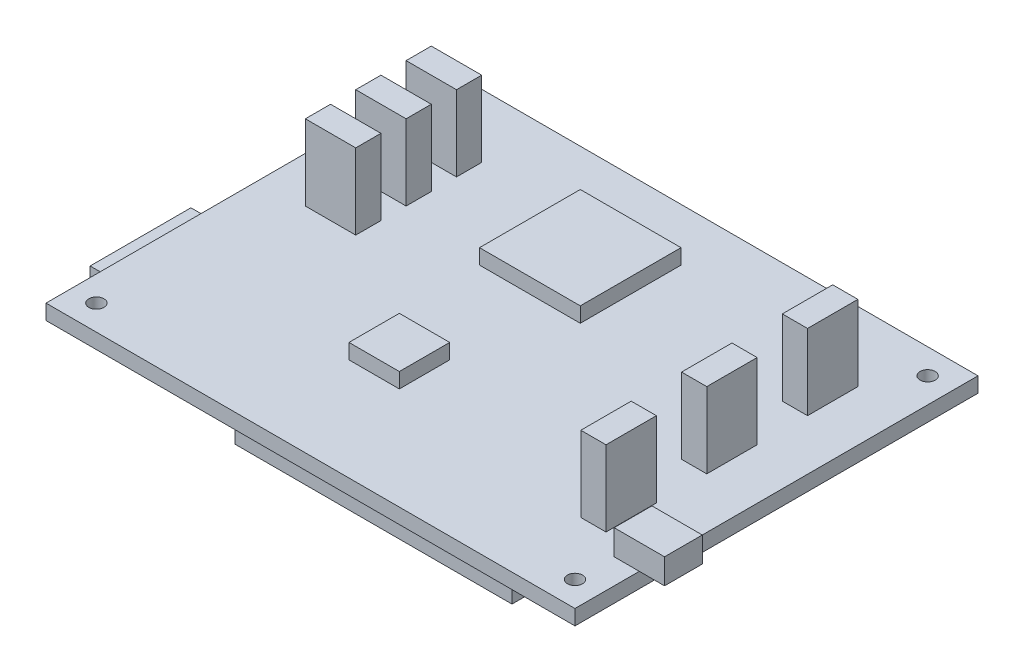
from build123d import *

# Parameters (mm, degrees)
ESQUISSE1_W      = 105
ESQUISSE1_H      = 80
ESQUISSE1_R      = 1.5
EXTRUSION1_DEPTH = 3
ESQUISSE2_W      = 20
ESQUISSE2_H      = 20
ESQUISSE2_W_2    = 10
ESQUISSE2_H_2    = 10
EXTRUSION2_DEPTH = 3
ESQUISSE3_W      = 5
ESQUISSE3_H      = 10
ESQUISSE3_W_2    = 10
ESQUISSE3_H_2    = 5
EXTRUSION3_DEPTH = 15
ESQUISSE4_W      = 55
ESQUISSE4_H      = 5
EXTRUSION4_DEPTH = 5
ESQUISSE5_W      = 30
ESQUISSE5_H      = 20
EXTRUSION5_DEPTH = 3
ESQUISSE6_W      = 10
ESQUISSE6_H      = 7.5
EXTRUSION6_DEPTH = 5


with BuildPart() as part:
    # Esquisse1 → Extrusion1 (new body)
    with BuildSketch(Plane(origin=(0, 0, 0), x_dir=(1, 0, 0), z_dir=(0, 1, 0))):
        with Locations((52.5, 40)):
            Rectangle(ESQUISSE1_W, ESQUISSE1_H)
        with Locations((5, 75)):
            Circle(ESQUISSE1_R, mode=Mode.SUBTRACT)
        with Locations((100, 75)):
            Circle(ESQUISSE1_R, mode=Mode.SUBTRACT)
        with Locations((100, 5)):
            Circle(ESQUISSE1_R, mode=Mode.SUBTRACT)
        with Locations((5, 5)):
            Circle(ESQUISSE1_R, mode=Mode.SUBTRACT)
    extrude(amount=EXTRUSION1_DEPTH)

    # Esquisse2 → Extrusion2 (add)
    with BuildSketch(Plane(origin=(0, 3, 0), x_dir=(1, 0, 0), z_dir=(0, 1, 0))):
        with Locations((46.498714715, 59.553685436)):
            Rectangle(ESQUISSE2_W, ESQUISSE2_H)
        with Locations((44.830735419, 25.305948149)):
            Rectangle(ESQUISSE2_W_2, ESQUISSE2_H_2)
    extrude(amount=EXTRUSION2_DEPTH)

    # Esquisse3 → Extrusion3 (add)
    with BuildSketch(Plane(origin=(0, 3, 0), x_dir=(1, 0, 0), z_dir=(0, 1, 0))):
        with Locations((92.438953264, 61.221664733)):
            Rectangle(ESQUISSE3_W, ESQUISSE3_H)
        with Locations((14.058039322, 64.92274654)):
            Rectangle(ESQUISSE3_W_2, ESQUISSE3_H_2)
        with Locations((14.058039322, 54.92274654)):
            Rectangle(ESQUISSE3_W_2, ESQUISSE3_H_2)
        with Locations((14.058039322, 44.92274654)):
            Rectangle(ESQUISSE3_W_2, ESQUISSE3_H_2)
        with Locations((92.438953264, 41.221664733)):
            Rectangle(ESQUISSE3_W, ESQUISSE3_H)
        with Locations((92.438953264, 21.221664733)):
            Rectangle(ESQUISSE3_W, ESQUISSE3_H)
    extrude(amount=EXTRUSION3_DEPTH)

    # Esquisse4 → Extrusion4 (add)
    with BuildSketch(Plane.XZ):
        with Locations((62.5, -5)):
            Rectangle(ESQUISSE4_W, ESQUISSE4_H)
        with Locations((62.5, -75)):
            Rectangle(ESQUISSE4_W, ESQUISSE4_H)
    extrude(amount=EXTRUSION4_DEPTH)

    # Esquisse5 → Extrusion5 (add)
    with BuildSketch(Plane.XZ):
        with Locations((10, -23.761311795)):
            Rectangle(ESQUISSE5_W, ESQUISSE5_H)
    extrude(amount=EXTRUSION5_DEPTH)

    # Esquisse6 → Extrusion6 (add)
    with BuildSketch(Plane(origin=(0, 3, 0), x_dir=(1, 0, 0), z_dir=(0, 1, 0))):
        with Locations((105, 16.524993395)):
            Rectangle(ESQUISSE6_W, ESQUISSE6_H)
    extrude(amount=EXTRUSION6_DEPTH)


solid = part.part
